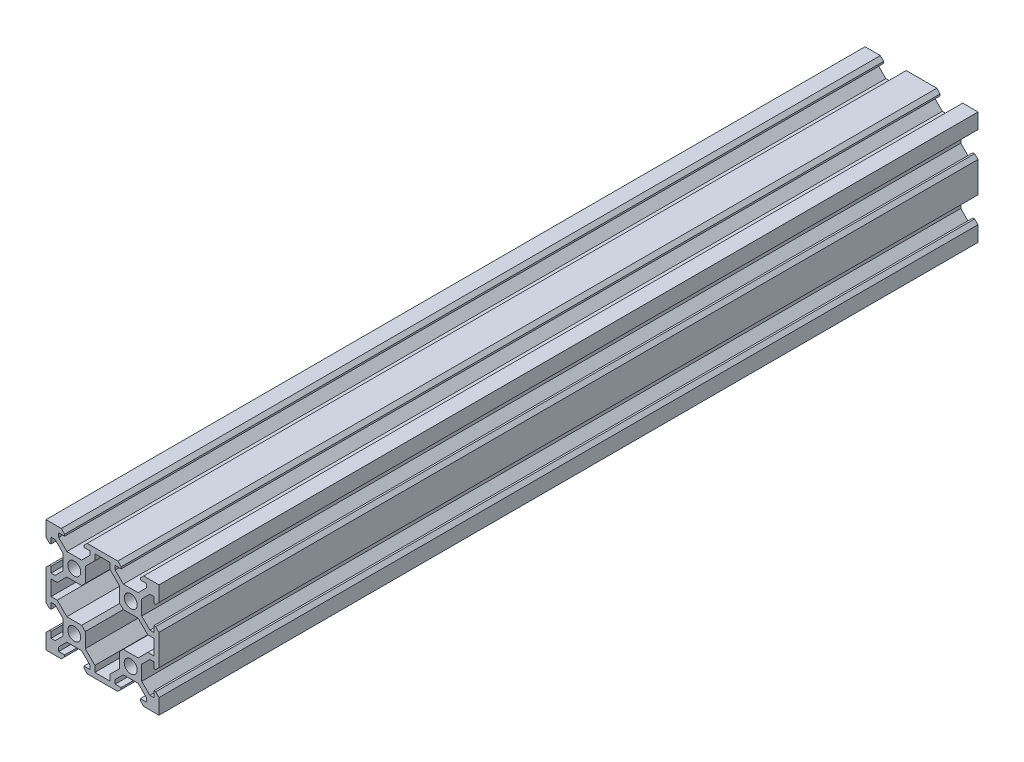
from build123d import *

# Parameters (mm, degrees)
SKETCH1_W           = 40
SKETCH1_H           = 40
BOSS_EXTRUDE1_DEPTH = 290
SKETCH2_R           = 2.3
CUT_EXTRUDE1_DEPTH  = 290
CUT_EXTRUDE2_DEPTH  = 290


with BuildPart() as part:
    # Sketch1 → Boss-Extrude1 (new body)
    with BuildSketch(Plane.XY):
        with Locations((20, 20)):
            Rectangle(SKETCH1_W, SKETCH1_H)
    extrude(amount=-BOSS_EXTRUDE1_DEPTH)

    # Sketch2 → Cut-Extrude1 (cut)
    with BuildSketch(Plane.XY):
        with Locations((10, 30)):
            Circle(SKETCH2_R)
        with Locations((30, 30)):
            Circle(SKETCH2_R)
        with Locations((30, 10)):
            Circle(SKETCH2_R)
        with Locations((10, 10)):
            Circle(SKETCH2_R)
        Polygon((6.605, 38.815), (6.605, 38.2), (4.5, 38.2), (4.5, 36.772792206), (7.372792206, 33.9), (12.627207794, 33.9), (15.5, 36.772792206), (15.5, 38.2), (13.395, 38.2), (13.395, 38.815), (14.58, 40), (5.42, 40), align=None)
        Polygon((26.605, 38.815), (25.42, 40), (34.58, 40), (33.395, 38.815), (33.395, 38.2), (35.5, 38.2), (35.5, 36.772792206), (32.627207794, 33.9), (27.372792206, 33.9), (24.5, 36.772792206), (24.5, 38.2), (26.605, 38.2), align=None)
        Polygon((26.605, 1.8), (26.605, 1.185), (25.42, 0), (34.58, 0), (33.395, 1.185), (33.395, 1.8), (35.5, 1.8), (35.5, 3.227207794), (32.627207794, 6.1), (27.372792206, 6.1), (24.5, 3.227207794), (24.5, 1.8), align=None)
        Polygon((13.395, 1.185), (14.58, 0), (5.42, 0), (6.605, 1.185), (6.605, 1.8), (4.5, 1.8), (4.5, 3.227207794), (7.372792206, 6.1), (12.627207794, 6.1), (15.5, 3.227207794), (15.5, 1.8), (13.395, 1.8), align=None)
        Polygon((1.8, 13.395), (1.185, 13.395), (0, 14.58), (0, 5.42), (1.185, 6.605), (1.8, 6.605), (1.8, 4.5), (3.227207794, 4.5), (6.1, 7.372792206), (6.1, 12.627207794), (3.227207794, 15.5), (1.8, 15.5), align=None)
        Polygon((1.185, 26.605), (0, 25.42), (0, 34.58), (1.185, 33.395), (1.8, 33.395), (1.8, 35.5), (3.227207794, 35.5), (6.1, 32.627207794), (6.1, 27.372792206), (3.227207794, 24.5), (1.8, 24.5), (1.8, 26.605), align=None)
        Polygon((38.2, 15.5), (38.2, 13.395), (38.815, 13.395), (40, 14.58), (40, 5.42), (38.815, 6.605), (38.2, 6.605), (38.2, 4.5), (36.772792206, 4.5), (33.9, 7.372792206), (33.9, 12.627207794), (36.772792206, 15.5), align=None)
        Polygon((38.2, 26.605), (38.815, 26.605), (40, 25.42), (40, 34.58), (38.815, 33.395), (38.2, 33.395), (38.2, 35.5), (36.772792206, 35.5), (33.9, 32.627207794), (33.9, 27.372792206), (36.772792206, 24.5), (38.2, 24.5), align=None)
    extrude(amount=-CUT_EXTRUDE1_DEPTH, mode=Mode.SUBTRACT)

    # Sketch3 → Cut-Extrude2 (cut)
    with BuildSketch(Plane.XY):
        Polygon((17.3, 38.2), (22.7, 38.2), (22.7, 36.027207794), (26.1, 32.627207794), (26.1, 27.372792206), (27.372792206, 26.1), (32.627207794, 26.1), (36.027207794, 22.7), (38.2, 22.7), (38.2, 17.3), (36.027207794, 17.3), (32.627207794, 13.9), (27.372792206, 13.9), (26.1, 12.627207794), (26.1, 7.372792206), (22.7, 3.972792206), (22.7, 1.8), (17.3, 1.8), (17.3, 3.972792206), (13.9, 7.372792206), (13.9, 12.627207794), (12.627207794, 13.9), (7.372792206, 13.9), (3.972792206, 17.3), (1.8, 17.3), (1.8, 22.7), (3.972792206, 22.7), (7.372792206, 26.1), (12.627207794, 26.1), (13.9, 27.372792206), (13.9, 32.627207794), (17.3, 36.027207794), align=None)
    extrude(amount=-CUT_EXTRUDE2_DEPTH, mode=Mode.SUBTRACT)


solid = part.part
